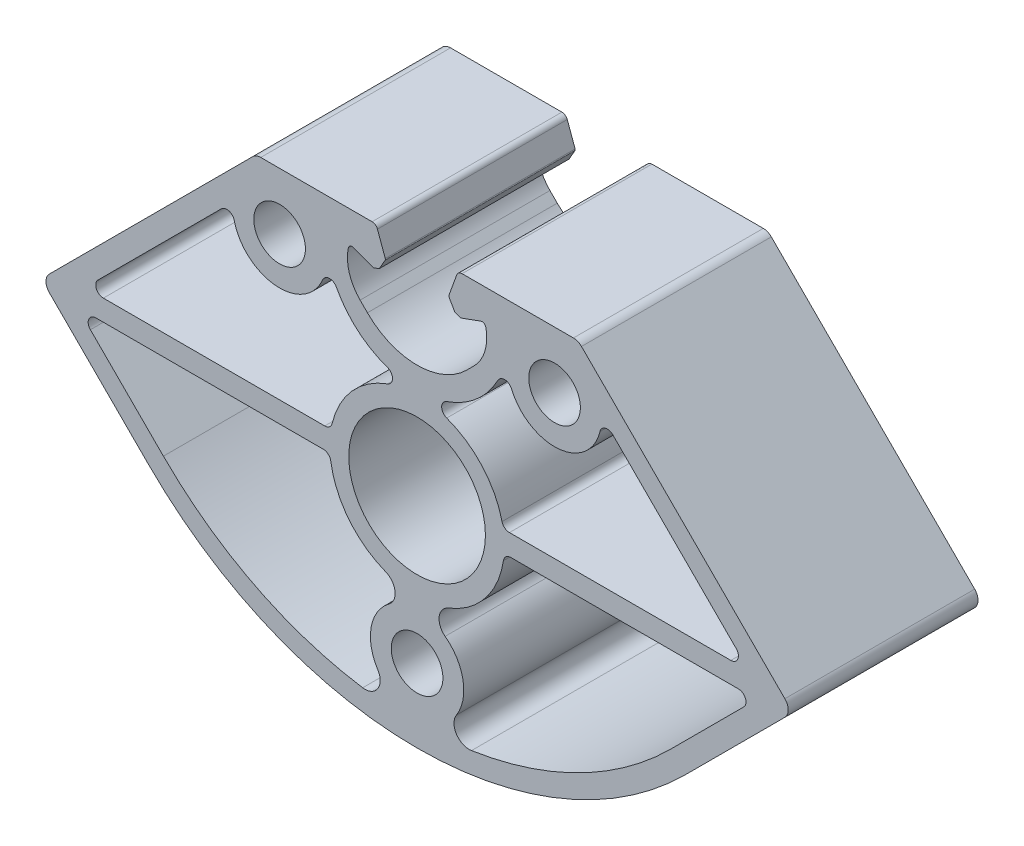
from build123d import *

# Parameters (mm, degrees)
SK_MAIN_EXTRUSION_R   = 3.4
SK_MAIN_EXTRUSION_R_2 = 9
MAIN_EXTRUSION_DEPTH  = 25


with BuildPart() as part:
    # Sk Main Extrusion → Main Extrusion (new body)
    with BuildSketch(Plane.XY):
        with BuildLine():
            Line((5.222054351, 27.806515107), (4.190076845, 24.971180212))
            ThreePointArc((4.190076845, 24.971180212), (4.175951325, 24.863886241), (4.208493649, 24.760675177))
            Line((4.208493649, 24.760675177), (4.987558066, 23.411296024))
            Line((4.987558066, 23.411296024), (5.718509166, 23.145251581))
            Line((5.718509166, 23.145251581), (8.396186179, 24.11984631))
            ThreePointArc((8.396186179, 24.11984631), (8.811074612, 24.086489799), (9.056960151, 23.750654467))
            ThreePointArc((9.056960151, 23.750654467), (8.933433013, 20.965882372), (7.504160339, 18.572684887))
            Line((7.504160339, 18.572684887), (6.540737726, 17.609262274))
            ThreePointArc((6.540737726, 17.609262274), (0, 14.9), (-6.540737726, 17.609262274))
            Line((-6.540737726, 17.609262274), (-7.504160339, 18.572684887))
            ThreePointArc((-7.504160339, 18.572684887), (-8.933433013, 20.965882372), (-9.056960151, 23.750654467))
            ThreePointArc((-9.056960151, 23.750654467), (-8.811074612, 24.086489799), (-8.396186179, 24.11984631))
            Line((-8.396186179, 24.11984631), (-5.718509166, 23.145251581))
            Line((-5.718509166, 23.145251581), (-4.987558066, 23.411296024))
            Line((-4.987558066, 23.411296024), (-4.208493649, 24.760675177))
            ThreePointArc((-4.208493649, 24.760675177), (-4.175951325, 24.863886241), (-4.190076845, 24.971180212))
            Line((-4.190076845, 24.971180212), (-5.222054351, 27.806515107))
            ThreePointArc((-5.222054351, 27.806515107), (-5.496641489, 28.164364033), (-5.926823816, 28.3))
            Line((-5.926823816, 28.3), (-20.591883092, 28.3))
            ThreePointArc((-20.591883092, 28.3), (-21.165908241, 28.185819299), (-21.652543264, 27.860660172))
            Line((-21.652543264, 27.860660172), (-48.436814511, 1.076388924))
            ThreePointArc((-48.436814511, 1.076388924), (-48.876154339, 0.015728753), (-48.436814511, -1.044931419))
            Line((-48.436814511, -1.044931419), (-35.355339059, -14.126406871))
            ThreePointArc((-35.355339059, -14.126406871), (0, -28.771067812), (35.355339059, -14.126406871))
            Line((35.355339059, -14.126406871), (48.436814511, -1.044931419))
            ThreePointArc((48.436814511, -1.044931419), (48.876154339, 0.015728753), (48.436814511, 1.076388924))
            Line((48.436814511, 1.076388924), (21.652543264, 27.860660172))
            ThreePointArc((21.652543264, 27.860660172), (21.165908241, 28.185819299), (20.591883092, 28.3))
            Line((20.591883092, 28.3), (5.926823816, 28.3))
            ThreePointArc((5.926823816, 28.3), (5.496641489, 28.164364033), (5.222054351, 27.806515107))
        make_face()
        with Locations((-18.106601718, 20.8)):
            Circle(SK_MAIN_EXTRUSION_R, mode=Mode.SUBTRACT)
        with Locations((18.106601718, 20.8)):
            Circle(SK_MAIN_EXTRUSION_R, mode=Mode.SUBTRACT)
        Circle(SK_MAIN_EXTRUSION_R_2, mode=Mode.SUBTRACT)
        with Locations((0, -19.1)):
            Circle(SK_MAIN_EXTRUSION_R, mode=Mode.SUBTRACT)
        with BuildLine():
            Line((33.410795411, -12.181863223), (43.025551853, -2.567106781))
            ThreePointArc((43.025551853, -2.567106781), (43.242324604, -1.477316568), (42.318445072, -0.86))
            Line((42.318445072, -0.86), (12.360841395, -0.86))
            ThreePointArc((12.360841395, -0.86), (11.708461138, -1.102108187), (11.371974084, -1.7112))
            ThreePointArc((11.371974084, -1.7112), (8.980737669, -7.183059997), (4.167977698, -10.718113729))
            ThreePointArc((4.167977698, -10.718113729), (2.911454942, -12.309920658), (3.692145622, -14.181609948))
            ThreePointArc((3.692145622, -14.181609948), (6.052344462, -18.008383533), (5.177787873, -22.418585955))
            ThreePointArc((5.177787873, -22.418585955), (5.184897798, -24.588029411), (7.164897408, -25.474673081))
            ThreePointArc((7.164897408, -25.474673081), (21.348803489, -20.923067641), (33.410795411, -12.181863223))
        make_face(mode=Mode.SUBTRACT)
        with BuildLine():
            Line((-12.360841395, -0.86), (-42.318445072, -0.86))
            ThreePointArc((-42.318445072, -0.86), (-43.242324604, -1.477316568), (-43.025551853, -2.567106781))
            Line((-43.025551853, -2.567106781), (-33.410795411, -12.181863223))
            ThreePointArc((-33.410795411, -12.181863223), (-21.348803489, -20.923067641), (-7.164897408, -25.474673081))
            ThreePointArc((-7.164897408, -25.474673081), (-5.184897798, -24.588029411), (-5.177787873, -22.418585955))
            ThreePointArc((-5.177787873, -22.418585955), (-6.052344462, -18.008383533), (-3.692145622, -14.181609948))
            ThreePointArc((-3.692145622, -14.181609948), (-2.911454942, -12.309920658), (-4.167977698, -10.718113729))
            ThreePointArc((-4.167977698, -10.718113729), (-8.980737669, -7.183059997), (-11.371974084, -1.7112))
            ThreePointArc((-11.371974084, -1.7112), (-11.708461138, -1.102108187), (-12.360841395, -0.86))
        make_face(mode=Mode.SUBTRACT)
        with BuildLine():
            Line((42.027009358, 3.597106781), (25.770007578, 19.854108561))
            ThreePointArc((25.770007578, 19.854108561), (24.790343945, 20.109141459), (24.089991835, 19.378190342))
            ThreePointArc((24.089991835, 19.378190342), (18.61547326, 14.671089024), (12.43962541, 18.410883107))
            ThreePointArc((12.43962541, 18.410883107), (11.559727537, 19.021544755), (10.632153091, 18.486069675))
            ThreePointArc((10.632153091, 18.486069675), (7.825100476, 14.952318837), (3.911288507, 12.705317448))
            ThreePointArc((3.911288507, 12.705317448), (3.237253104, 11.76683924), (3.898250879, 10.819133056))
            ThreePointArc((3.898250879, 10.819133056), (8.576111128, 7.661613271), (11.188421808, 2.6588))
            ThreePointArc((11.188421808, 2.6588), (11.541328052, 2.10539819), (12.161328052, 1.89))
            Line((12.161328052, 1.89), (41.319902577, 1.89))
            ThreePointArc((41.319902577, 1.89), (42.243782109, 2.507316568), (42.027009358, 3.597106781))
        make_face(mode=Mode.SUBTRACT)
        with BuildLine():
            Line((-25.770007578, 19.854108561), (-42.027009358, 3.597106781))
            ThreePointArc((-42.027009358, 3.597106781), (-42.243782109, 2.507316568), (-41.319902577, 1.89))
            Line((-41.319902577, 1.89), (-12.161328052, 1.89))
            ThreePointArc((-12.161328052, 1.89), (-11.541328052, 2.10539819), (-11.188421808, 2.6588))
            ThreePointArc((-11.188421808, 2.6588), (-8.576111128, 7.661613271), (-3.898250879, 10.819133056))
            ThreePointArc((-3.898250879, 10.819133056), (-3.237253104, 11.76683924), (-3.911288507, 12.705317448))
            ThreePointArc((-3.911288507, 12.705317448), (-7.825100476, 14.952318837), (-10.632153091, 18.486069675))
            ThreePointArc((-10.632153091, 18.486069675), (-11.559727537, 19.021544755), (-12.43962541, 18.410883107))
            ThreePointArc((-12.43962541, 18.410883107), (-18.61547326, 14.671089024), (-24.089991835, 19.378190342))
            ThreePointArc((-24.089991835, 19.378190342), (-24.790343945, 20.109141459), (-25.770007578, 19.854108561))
        make_face(mode=Mode.SUBTRACT)
    extrude(amount=-MAIN_EXTRUSION_DEPTH)


solid = part.part
